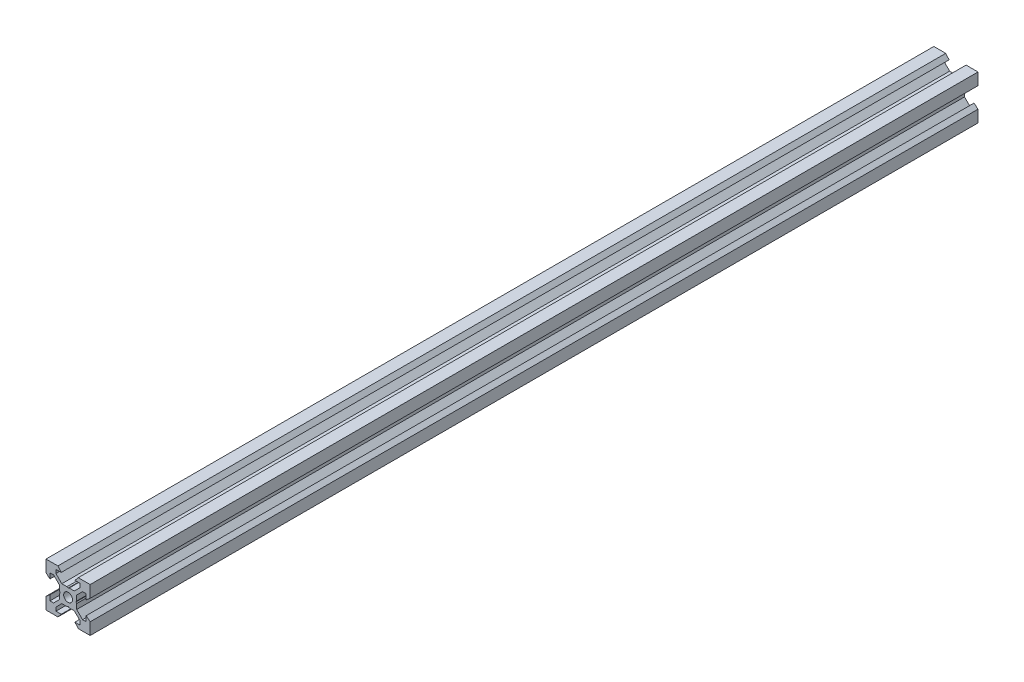
from build123d import *

# Parameters (mm, degrees)
SKETCH1_R           = 2
BOSS_EXTRUDE1_DEPTH = 201


with BuildPart() as part:
    # Sketch1 → Boss-Extrude1 (new body, symmetric)
    with BuildSketch(Plane.XY):
        Polygon((10, 10), (10, 4.610379336), (8.2, 3.1), (8.2, 5.5), (6.560660172, 5.5), (3.9, 2.839339828), (3.9, 0.519615242), (3.6, 0), (3.9, -0.519615242), (3.9, -2.839339828), (6.560660172, -5.5), (8.2, -5.5), (8.2, -3.1), (10, -4.610379336), (10, -10), (4.610379336, -10), (3.1, -8.2), (5.5, -8.2), (5.5, -6.560660172), (2.839339828, -3.9), (0.519615242, -3.9), (0, -3.6), (-0.519615242, -3.9), (-2.839339828, -3.9), (-5.5, -6.560660172), (-5.5, -8.2), (-3.1, -8.2), (-4.610379336, -10), (-10, -10), (-10, -4.610379336), (-8.2, -3.1), (-8.2, -5.5), (-6.560660172, -5.5), (-3.9, -2.839339828), (-3.9, -0.519615242), (-3.6, 0), (-3.9, 0.519615242), (-3.9, 2.839339828), (-6.560660172, 5.5), (-8.2, 5.5), (-8.2, 3.1), (-10, 4.610379336), (-10, 10), (-4.610379336, 10), (-3.1, 8.2), (-5.5, 8.2), (-5.5, 6.560660172), (-2.839339828, 3.9), (-0.519615242, 3.9), (0, 3.6), (0.519615242, 3.9), (2.839339828, 3.9), (5.5, 6.560660172), (5.5, 8.2), (3.1, 8.2), (4.610379336, 10), align=None)
        Circle(SKETCH1_R, mode=Mode.SUBTRACT)
    extrude(amount=BOSS_EXTRUDE1_DEPTH, both=True)


solid = part.part
